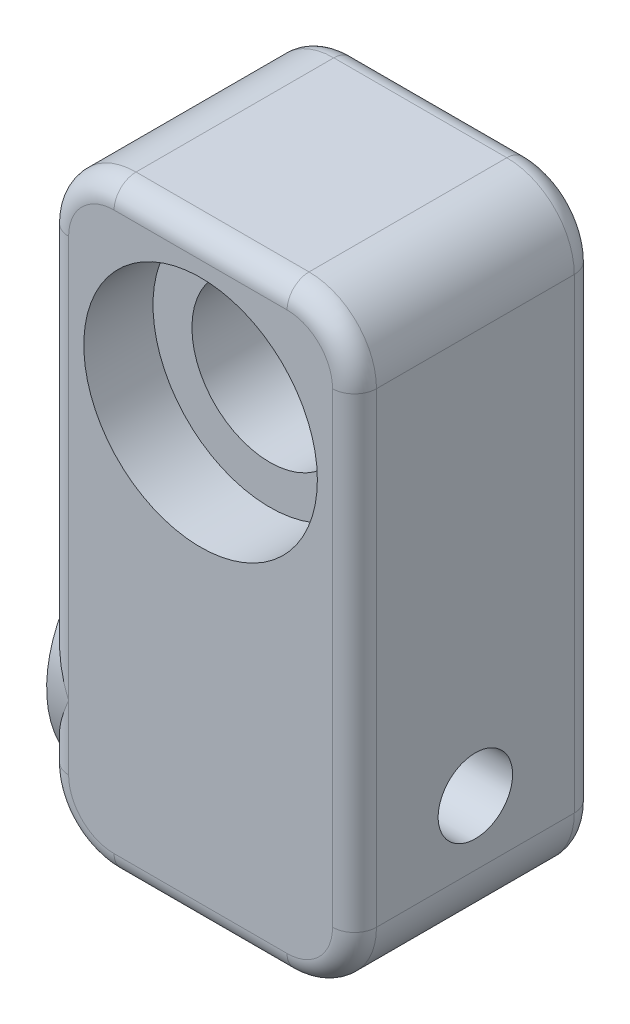
from build123d import *

# Parameters (mm, degrees)
BOSS_EXTRUDE1_DEPTH            = 13.97
FILLET1_R                      = 1.27
CBORE_FOR_M8_SHCS1_D           = 9
CBORE_FOR_M8_SHCS1_CBORE_D     = 13.5
CBORE_FOR_M8_SHCS1_CBORE_DEPTH = 4
M4_CLEARANCE_HOLE1_D           = 4.3
SKETCH6_R                      = 4.5
CUT_EXTRUDE1_DEPTH             = 4
BOSS_EXTRUDE3_REACH            = 19.794
SKETCH9_R                      = 6.985
SKETCH9_R_2                    = 2.15


with BuildPart() as part:
    # Sketch1 → Boss-Extrude1 (new body)
    with BuildSketch(Plane.XY):
        with BuildLine():
            Line((-8.897, -5), (-8.897, -21.956))
            ThreePointArc((-8.897, -21.956), (-7.755595126, -24.711595126), (-5, -25.853))
            Line((-5, -25.853), (5, -25.853))
            ThreePointArc((5, -25.853), (7.755595126, -24.711595126), (8.897, -21.956))
            Line((8.897, -21.956), (8.897, -5))
            Line((8.897, -5), (8.897, 5))
            ThreePointArc((8.897, 5), (7.755595126, 7.755595126), (5, 8.897))
            Line((5, 8.897), (-5, 8.897))
            ThreePointArc((-5, 8.897), (-7.755595126, 7.755595126), (-8.897, 5))
            Line((-8.897, 5), (-8.897, -5))
        make_face()
    extrude(amount=BOSS_EXTRUDE1_DEPTH)

    # Fillet1
    fillet1_edges = [part.edges().sort_by_distance(p)[0] for p in [
        (-7.755595126, -24.711595126, 13.97),
        (7.755595126, 7.755595126, 0),
        (8.897, -8.478, 0),
        (7.755595126, -24.711595126, 0),
        (0, -25.853, 0),
        (-7.755595126, -24.711595126, 0),
        (-8.897, -8.478, 0),
        (0, -25.853, 13.97),
        (7.755595126, -24.711595126, 13.97),
        (8.897, -8.478, 13.97),
        (7.755595126, 7.755595126, 13.97),
        (0, 8.897, 13.97),
        (-7.755595126, 7.755595126, 13.97),
        (-8.897, -8.478, 13.97),
        (-7.755595126, 7.755595126, 0),
        (0, 8.897, 0),
    ]]
    fillet(fillet1_edges, radius=FILLET1_R)

    # CBORE for M8 SHCS1 (through all)
    with Locations(Plane.XY.offset(13.97)):
        with Locations((0, 0)):
            CounterBoreHole(CBORE_FOR_M8_SHCS1_D / 2, CBORE_FOR_M8_SHCS1_CBORE_D / 2, CBORE_FOR_M8_SHCS1_CBORE_DEPTH)

    # M4 Clearance Hole1 (through all)
    with Locations(Plane(origin=(8.897, 0, 0), x_dir=(0, 0, -1), z_dir=(1, 0, 0))):
        with Locations((-6.985, -18.233)):
            Hole(M4_CLEARANCE_HOLE1_D / 2)

    # Sketch6 → Cut-Extrude1 (cut)
    with BuildSketch(Plane.XY):
        Circle(SKETCH6_R)
        Polygon((-3.75277675, 6.5), (-7.505553499, 0), (-3.75277675, -6.5), (3.75277675, -6.5), (7.505553499, 0), (3.75277675, 6.5), align=None)
        Polygon((-3.25, 5.629165125), (-6.5, 3.75277675), (-6.5, 0), (-6.5, -3.75277675), (-3.25, -5.629165125), (0, -7.505553499), (3.25, -5.629165125), (6.5, -3.75277675), (6.5, 0), (6.5, 3.75277675), (3.25, 5.629165125), (0, 7.505553499), align=None)
        Polygon((6.5, 3.75277675), (4.758330249, 4.758330249), (6.5, 1.741669751), align=None)
        Polygon((6.5, -3.75277675), (6.5, -1.741669751), (4.758330249, -4.758330249), align=None)
        Polygon((3.75277675, -6.5), (4.758330249, -4.758330249), (3.25, -5.629165125), (1.741669751, -6.5), align=None)
        Polygon((1.741669751, 6.5), (3.25, 5.629165125), (4.758330249, 4.758330249), (3.75277675, 6.5), align=None)
        Polygon((-6.5, 1.741669751), (-4.758330249, 4.758330249), (-6.5, 3.75277675), align=None)
        Polygon((-4.758330249, -4.758330249), (-6.5, -1.741669751), (-6.5, -3.75277675), align=None)
        Polygon((-3.25, -5.629165125), (-4.758330249, -4.758330249), (-3.75277675, -6.5), (-1.741669751, -6.5), align=None)
        Polygon((0, -7.505553499), (1.741669751, -6.5), (-1.741669751, -6.5), align=None)
        Polygon((-3.25, 5.629165125), (-1.741669751, 6.5), (-3.75277675, 6.5), (-4.758330249, 4.758330249), align=None)
        Polygon((7.505553499, 0), (6.5, 1.741669751), (6.5, 0), (6.5, -1.741669751), align=None)
        Polygon((-1.741669751, 6.5), (1.741669751, 6.5), (0, 7.505553499), align=None)
        Polygon((-6.5, 0), (-6.5, 1.741669751), (-7.505553499, 0), (-6.5, -1.741669751), align=None)
    extrude(amount=CUT_EXTRUDE1_DEPTH, mode=Mode.SUBTRACT)

    # Sketch9 → Boss-Extrude3 (add, up to next)
    with BuildSketch(Plane.ZY.offset(8.897), mode=Mode.PRIVATE) as boss_extrude3_sk1:
        with Locations((6.985, -18.233)):
            Circle(SKETCH9_R)
        with Locations((6.985, -18.233)):
            Circle(SKETCH9_R_2, mode=Mode.SUBTRACT)
    boss_extrude3_tool1 = extrude(boss_extrude3_sk1.sketch, amount=-BOSS_EXTRUDE3_REACH, mode=Mode.PRIVATE) - part.part
    add(boss_extrude3_tool1.solids().sort_by_distance((-8.897, -18.233, 0.197566))[0])


solid = part.part
